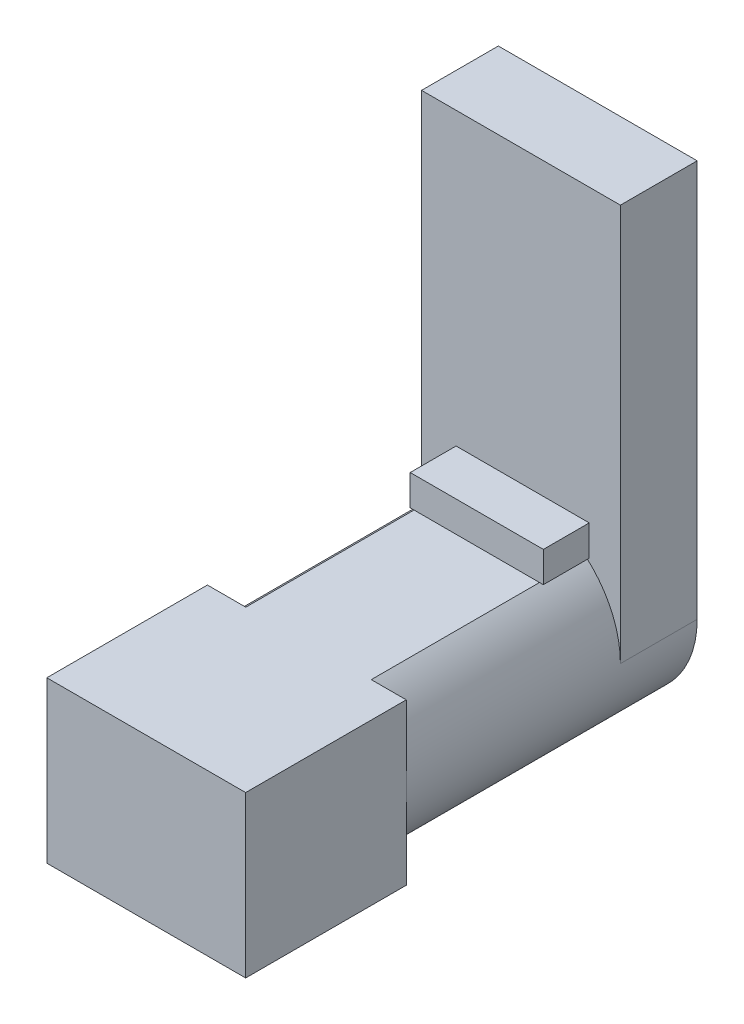
from build123d import *

# Parameters (mm, degrees)
SKETCH2_W            = 13
SKETCH2_H            = 11.1
SKETCH2_W_2          = 12.5
SKETCH2_H_2          = 10.6
BOSS_EXTRUDE1_DEPTH  = 10
SKETCH3_W            = 12.5
SKETCH3_H            = 10.6
BOSS_EXTRUDE2_DEPTH  = 10
BOSS_EXTRUDE3_DEPTH  = 15.5
BOSS_EXTRUDE4_DEPTH  = 1.5
BOSS_EXTRUDE5_DEPTH  = 3.52
SKETCH9_W            = 13
SKETCH9_H            = 11.1
BOSS_EXTRUDE7_DEPTH  = 0.5
SKETCH10_W           = 24.5
SKETCH10_H           = 0.6
CUT_EXTRUDE1_DEPTH   = 15
BOSS_EXTRUDE8_DEPTH  = 3
SKETCH13_R           = 4.75
BOSS_EXTRUDE9_DEPTH  = 0.98
SKETCH15_W           = 13
SKETCH15_H           = 5.02
BOSS_EXTRUDE11_DEPTH = 15


with BuildPart() as part:
    # Sketch2 → Boss-Extrude1 (new body)
    with BuildSketch(Plane.XY):
        Rectangle(SKETCH2_W, SKETCH2_H)
        Rectangle(SKETCH2_W_2, SKETCH2_H_2, mode=Mode.SUBTRACT)
    extrude(amount=BOSS_EXTRUDE1_DEPTH)

    # Sketch3 → Boss-Extrude2 (add)
    with BuildSketch(Plane(origin=(0, 0, 0), x_dir=(-1, 0, 0), z_dir=(0, 0, -1))):
        Rectangle(SKETCH3_W, SKETCH3_H)
    extrude(amount=-BOSS_EXTRUDE2_DEPTH)

    # Sketch4 → Boss-Extrude3 (add)
    with BuildSketch(Plane(origin=(0, 0, 0), x_dir=(-1, 0, 0), z_dir=(0, 0, -1))):
        with BuildLine():
            Line((-3.383415434, -5.55), (2.983923173, -5.55))
            ThreePointArc((2.983923173, -5.55), (6.5, 0), (2.983923173, 5.55))
            Line((2.983923173, 5.55), (-3.383415434, 5.55))
            ThreePointArc((-3.383415434, 5.55), (-6.5, 0), (-3.383415434, -5.55))
        make_face()
    extrude(amount=BOSS_EXTRUDE3_DEPTH)

    # Sketch5 → Boss-Extrude4 (add)
    with BuildSketch(Plane(origin=(0, 0, -15.5), x_dir=(-1, 0, 0), z_dir=(0, 0, -1))):
        with BuildLine():
            Line((6.5, 0), (-6.5, 0))
            ThreePointArc((-6.5, 0), (-5.667547985, -3.182593257), (-3.383415434, -5.55))
            Line((-3.383415434, -5.55), (2.983923173, -5.55))
            ThreePointArc((2.983923173, -5.55), (5.547001926, -3.285015078), (6.5, 0))
        make_face()
        with BuildLine():
            Line((6.5, 10.96), (-6.5, 10.96))
            Line((-6.5, 10.96), (-6.5, 0))
            ThreePointArc((-6.5, 0), (-5.667547985, 3.182593257), (-3.383415434, 5.55))
            Line((-3.383415434, 5.55), (2.983923173, 5.55))
            ThreePointArc((2.983923173, 5.55), (5.547001926, 3.285015078), (6.5, 0))
            Line((6.5, 0), (6.5, 10.96))
        make_face()
    extrude(amount=-BOSS_EXTRUDE4_DEPTH)

    # Sketch6 → Boss-Extrude5 (add)
    with BuildSketch(Plane(origin=(0, 0, -15.5), x_dir=(-1, 0, 0), z_dir=(0, 0, -1))):
        with BuildLine():
            Line((-6.5, 0), (-6.5, 10.96))
            Line((-6.5, 10.96), (6.5, 10.96))
            Line((6.5, 10.96), (6.5, 0))
            ThreePointArc((6.5, 0), (5.547001926, -3.285015078), (2.983923173, -5.55))
            Line((2.983923173, -5.55), (-3.383415434, -5.55))
            ThreePointArc((-3.383415434, -5.55), (-5.667547985, -3.182593257), (-6.5, 0))
        make_face()
    extrude(amount=BOSS_EXTRUDE5_DEPTH)

    # Sketch9 → Boss-Extrude7 (add)
    with BuildSketch(Plane.XY.offset(10)):
        Rectangle(SKETCH9_W, SKETCH9_H)
    extrude(amount=BOSS_EXTRUDE7_DEPTH)

    # Sketch10 → Cut-Extrude1 (cut)
    with BuildSketch(Plane.ZY.offset(6.5)):
        with Locations((-1.75, 5.25)):
            Rectangle(SKETCH10_W, SKETCH10_H)
    extrude(amount=-CUT_EXTRUDE1_DEPTH, mode=Mode.SUBTRACT)

    # Sketch11 → Boss-Extrude8 (add)
    with BuildSketch(Plane.XY.offset(-14)):
        Polygon((-3.991590331, 4.95), (0.110593925, 4.95), (0.110593925, 6.95), (-4.241590331, 6.95), (-4.241590331, 4.95), align=None)
        Polygon((4.212778181, 4.95), (4.462778181, 4.95), (4.462778181, 6.95), (0.110593925, 6.95), (0.110593925, 4.95), align=None)
    extrude(amount=BOSS_EXTRUDE8_DEPTH)

    # Sketch13 → Boss-Extrude9 (add)
    with BuildSketch(Plane(origin=(0, 0, -19.02), x_dir=(-1, 0, 0), z_dir=(0, 0, -1))):
        with Locations((-0.048060538, -0.29)):
            Circle(SKETCH13_R)
    extrude(amount=BOSS_EXTRUDE9_DEPTH)

    # Sketch15 → Boss-Extrude11 (add)
    with BuildSketch(Plane(origin=(0, 10.96, 0), x_dir=(1, 0, 0), z_dir=(0, 1, 0))):
        with Locations((0, 16.51)):
            Rectangle(SKETCH15_W, SKETCH15_H)
    extrude(amount=BOSS_EXTRUDE11_DEPTH)


solid = part.part
